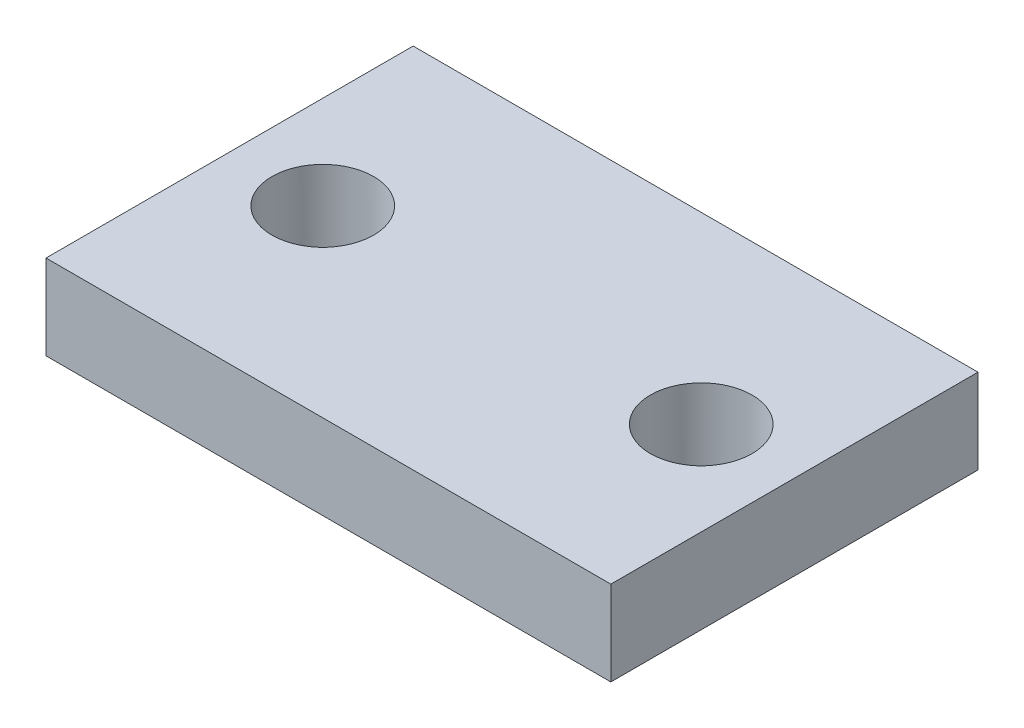
from build123d import *

# Parameters (mm, degrees)
SKETCH1_W               = 20
SKETCH1_H               = 13
BOSS_EXTRUDE1_DEPTH     = 3
SKETCH2_R               = 1.8
CUT_EXTRUDE1_DEPTH      = 1
CUT_EXTRUDE1_DEPTH_BACK = 4


with BuildPart() as part:
    # Sketch1 → Boss-Extrude1 (new body)
    with BuildSketch(Plane(origin=(0, 0, 0), x_dir=(1, 0, 0), z_dir=(0, 1, 0))):
        with Locations((10, 6.5)):
            Rectangle(SKETCH1_W, SKETCH1_H)
    extrude(amount=BOSS_EXTRUDE1_DEPTH)

    # Sketch2 → Cut-Extrude1 (cut, two sides)
    with BuildSketch(Plane(origin=(0, 3, 0), x_dir=(1, 0, 0), z_dir=(0, 1, 0))) as cut_extrude1_sk:
        with Locations((3.3, 6.5)):
            Circle(SKETCH2_R)
        with Locations((16.7, 6.5)):
            Circle(SKETCH2_R)
    extrude(amount=CUT_EXTRUDE1_DEPTH, mode=Mode.SUBTRACT)
    extrude(cut_extrude1_sk.sketch, amount=-CUT_EXTRUDE1_DEPTH_BACK, mode=Mode.SUBTRACT)


solid = part.part
